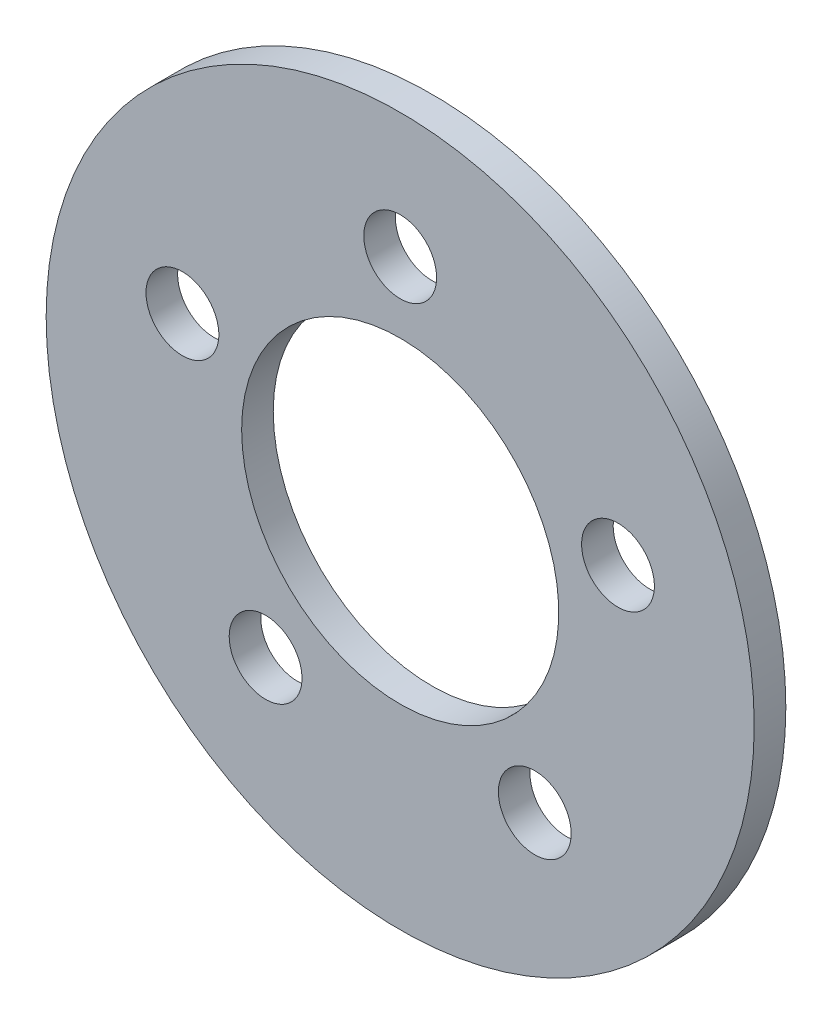
from build123d import *

# Parameters (mm, degrees)
SKETCH3_R           = 17.78
SKETCH3_R_2         = 7.9629
SKETCH3_R_3         = 1.8288
BOSS_EXTRUDE2_DEPTH = 1.5875


with BuildPart() as part:
    # Sketch3 → Boss-Extrude2 (new body)
    with BuildSketch(Plane(origin=(0, 0, -15.875), x_dir=(-1, 0, 0), z_dir=(0, 0, -1))):
        Circle(SKETCH3_R)
        Circle(SKETCH3_R_2, mode=Mode.SUBTRACT)
        with Locations((-6.759530401, -9.303695435)):
            Circle(SKETCH3_R_3, mode=Mode.SUBTRACT)
        with Locations((6.759530401, -9.303695435)):
            Circle(SKETCH3_R_3, mode=Mode.SUBTRACT)
        with Locations((10.937149937, 3.553695435)):
            Circle(SKETCH3_R_3, mode=Mode.SUBTRACT)
        with Locations((0, 11.5)):
            Circle(SKETCH3_R_3, mode=Mode.SUBTRACT)
        with Locations((-10.937149937, 3.553695435)):
            Circle(SKETCH3_R_3, mode=Mode.SUBTRACT)
    extrude(amount=BOSS_EXTRUDE2_DEPTH)


solid = part.part
